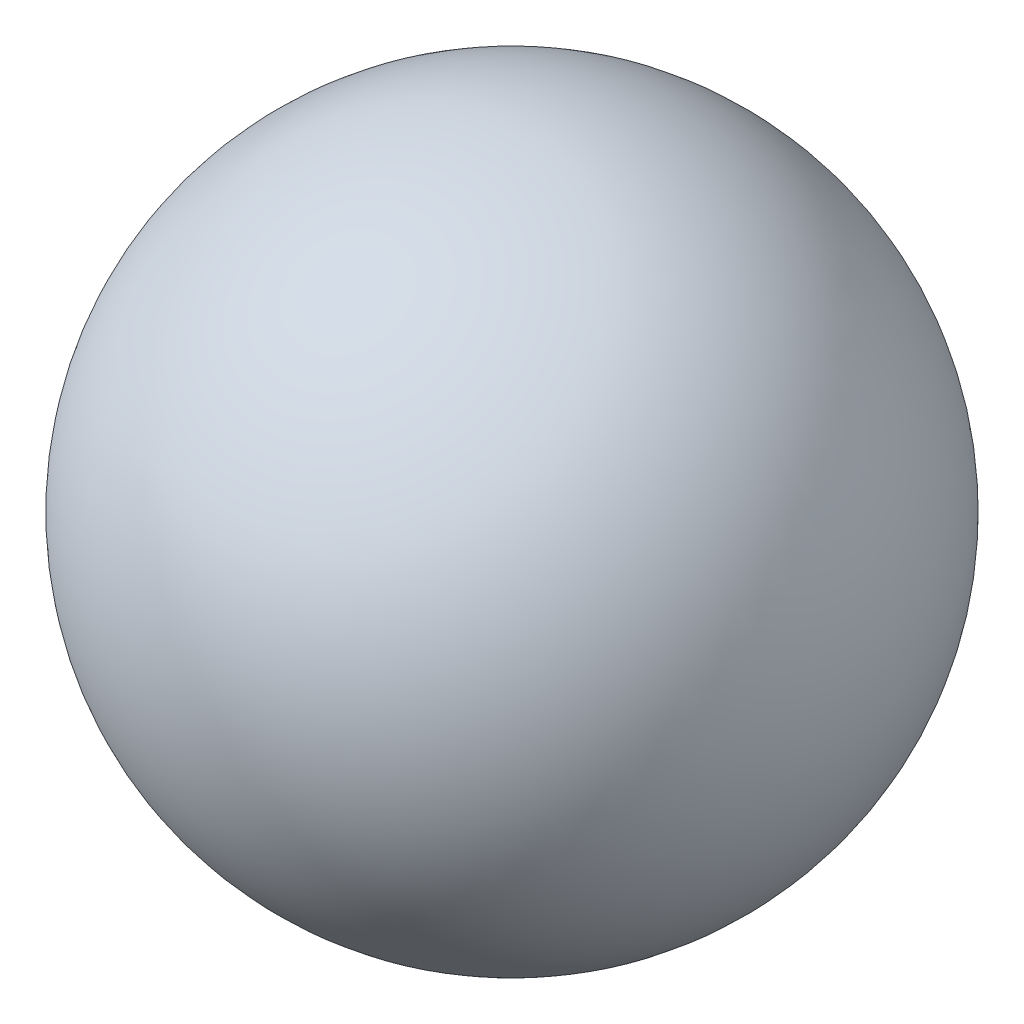
from build123d import *


with BuildPart() as part:
    # Sketch1 → Revolve1 (revolve)
    with BuildSketch(Plane.XY):
        with BuildLine():
            Line((0, -1.5), (0, 1.5))
            ThreePointArc((0, 1.5), (1.5, 0), (0, -1.5))
        make_face()
    revolve(axis=Axis((0, -1.5, 0), (0, 1, 0)))


solid = part.part
